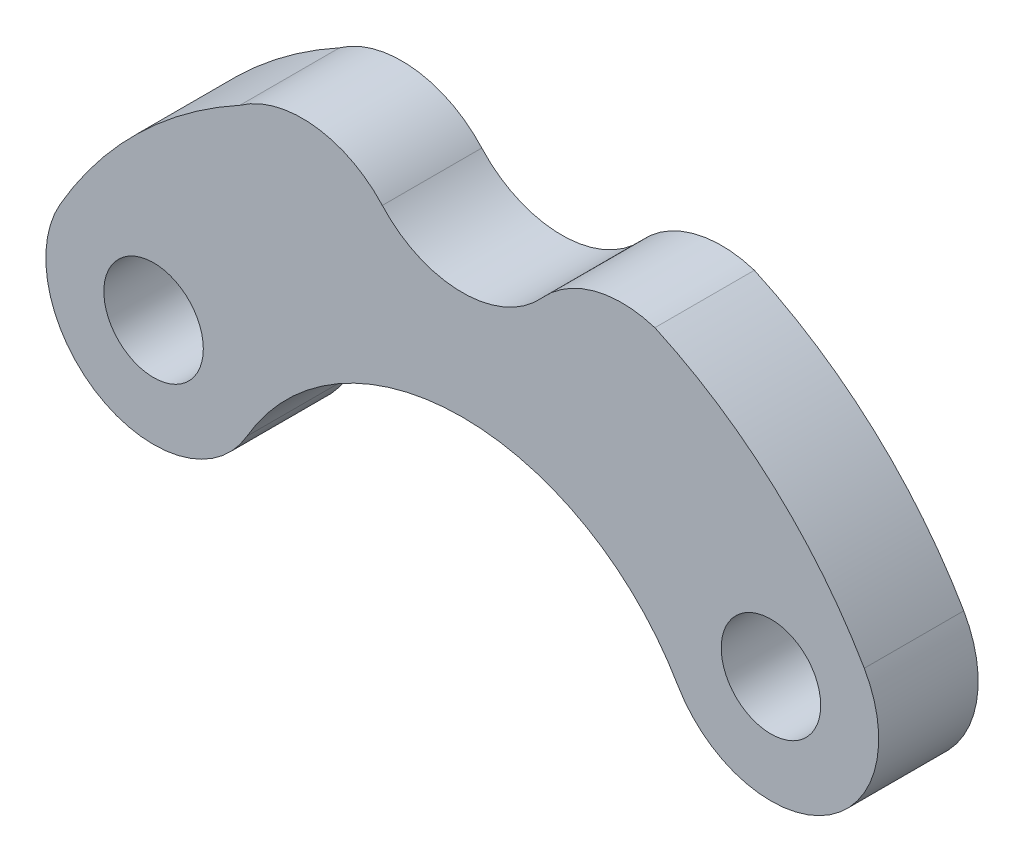
from build123d import *

# Parameters (mm, degrees)
ESQUISSE1_R        = 1.5
BOSS_EXTRU_2_DEPTH = 3


with BuildPart() as part:
    # Esquisse1 → Boss.-Extru.2 (new body)
    with BuildSketch(Plane.XY):
        with BuildLine():
            ThreePointArc((-2.411034891, 11.820685714), (0, 10.75), (2.411034891, 11.820685714))
            ThreePointArc((2.411034891, 11.820685714), (3.975330286, 12.779130538), (5.80943088, 12.737759334))
            ThreePointArc((5.80943088, 12.737759334), (9.414650572, 10.36167721), (12.124355653, 7))
            ThreePointArc((12.124355653, 7), (10.934773091, 2.560417438), (6.495190528, 3.75))
            ThreePointArc((6.495190528, 3.75), (0, 7.5), (-6.495190528, 3.75))
            ThreePointArc((-6.495190528, 3.75), (-10.934773091, 2.560417438), (-12.124355653, 7))
            ThreePointArc((-12.124355653, 7), (-9.780131311, 10.017436376), (-6.707371512, 12.288660114))
            ThreePointArc((-6.707371512, 12.288660114), (-4.47014813, 12.872261577), (-2.411034891, 11.820685714))
        make_face()
        with Locations((9.309773091, 5.375)):
            Circle(ESQUISSE1_R, mode=Mode.SUBTRACT)
        with Locations((-9.309773091, 5.375)):
            Circle(ESQUISSE1_R, mode=Mode.SUBTRACT)
    extrude(amount=BOSS_EXTRU_2_DEPTH)


solid = part.part
